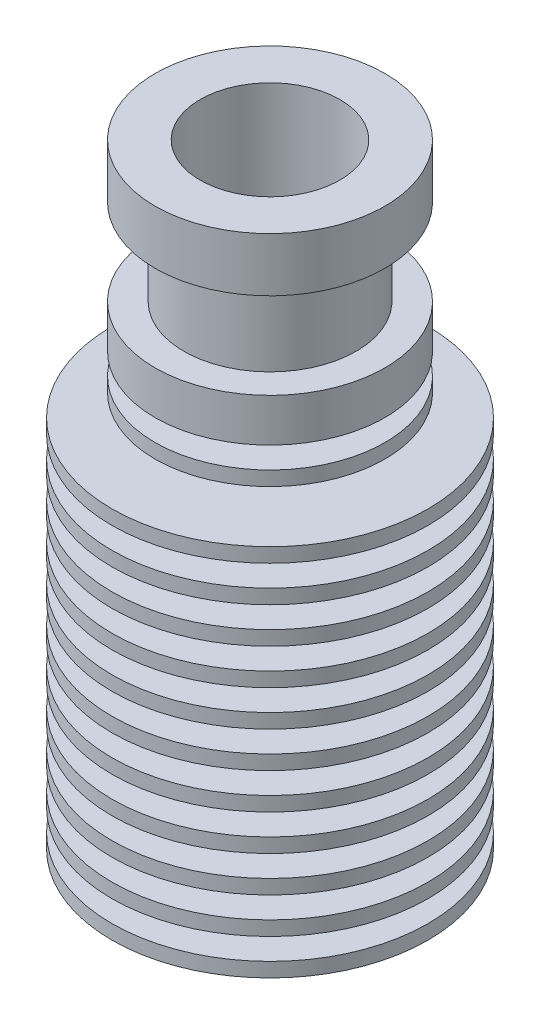
from build123d import *


with BuildPart() as part:
    # Sketch1 → Revolve1 (revolve)
    with BuildSketch(Plane.XY):
        Polygon((3, -21.375), (11, -21.375), (11, -20.375), (4, -20.375), (4, -18.875), (11, -18.875), (11, -17.875), (4, -17.875), (4, -16.375), (11, -16.375), (11, -15.375), (4, -15.375), (4, -13.875), (11, -13.875), (11, -12.875), (4, -12.875), (4, -11.375), (11, -11.375), (11, -10.375), (4, -10.375), (4, -8.875), (11, -8.875), (11, -7.875), (4, -7.875), (4, -6.375), (11, -6.375), (11, -5.375), (4, -5.375), (4, -3.875), (11, -3.875), (11, -2.875), (4, -2.875), (4, -1.375), (11, -1.375), (11, -0.375), (4, -0.375), (4, 1.125), (11, 1.125), (11, 2.125), (4, 2.125), (4, 3.625), (11, 3.625), (11, 4.625), (4, 4.625), (4, 6.125), (8, 6.125), (8, 7.125), (4, 7.125), (4, 8.625), (8, 8.625), (8, 11.625), (6, 11.625), (6, 17.625), (8, 17.625), (8, 21.375), (4.8641, 21.375), (4.8641, 11.375), (2, 6.414233282), (2, 2.414233282), (1, 1.836883013), (1, -5.895299462), (3, -7.05), align=None)
    revolve(axis=Axis((0, -21.375, 0), (0, 1, 0)))


solid = part.part
